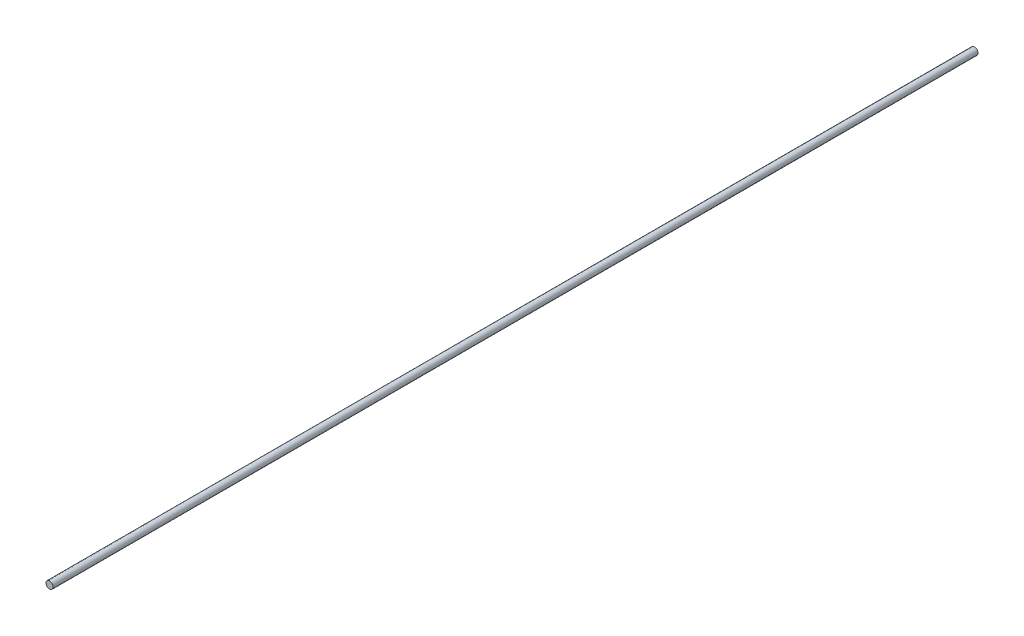
from build123d import *

# Parameters (mm, degrees)
SKETCH1_R           = 4
BOSS_EXTRUDE1_DEPTH = 1040


with BuildPart() as part:
    # Sketch1 → Boss-Extrude1 (new body)
    with BuildSketch(Plane.XY):
        Circle(SKETCH1_R)
    extrude(amount=BOSS_EXTRUDE1_DEPTH)


solid = part.part
